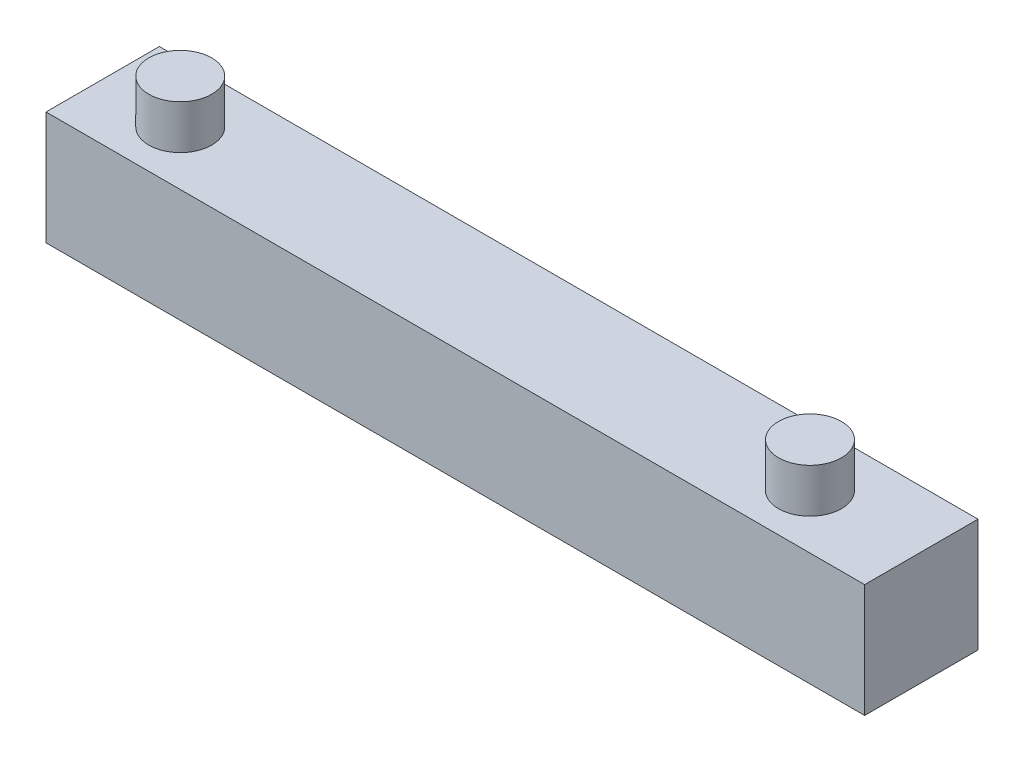
from build123d import *

# Parameters (mm, degrees)
SKETCH1_W           = 650
SKETCH1_H           = 90
BOSS_EXTRUDE1_DEPTH = 90
SKETCH2_R           = 25
BOSS_EXTRUDE2_DEPTH = 35


with BuildPart() as part:
    # Sketch1 → Boss-Extrude1 (new body)
    with BuildSketch(Plane.XY):
        with Locations((325, 45)):
            Rectangle(SKETCH1_W, SKETCH1_H)
    extrude(amount=BOSS_EXTRUDE1_DEPTH)

    # Sketch2 → Boss-Extrude2 (add)
    with BuildSketch(Plane(origin=(0, 90, 0), x_dir=(1, 0, 0), z_dir=(0, 1, 0))):
        with Locations(Location((63.60842931, -47.01070439, 0), (0, 0, 90))):  # turned: the seam where the file's is
            Circle(SKETCH2_R)
        with Locations(Location((563.60842931, -47.01070439, 0), (0, 0, 90))):  # turned: the seam where the file's is
            Circle(SKETCH2_R)
    extrude(amount=BOSS_EXTRUDE2_DEPTH)


solid = part.part
